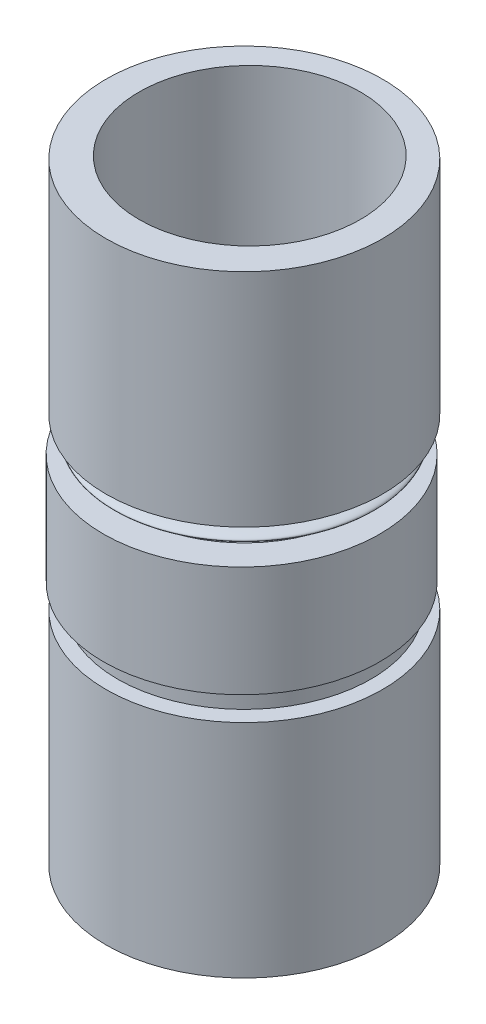
from build123d import *

# Parameters (mm, degrees)
SKETCH_2_R      = 6.25
SKETCH_2_R_2    = 5
EXTRUDE_1_DEPTH = 10
EXTRUDE_START   = 0.15
SKETCH_3_R      = 5.731622833
EXTRUDE_2_DEPTH = 0.75
EXTRUDE_START_2 = 0.25
SKETCH_4_R      = 6.25
SKETCH_4_R_2    = 5
EXTRUDE_3_DEPTH = 5
EXTRUDE_START_3 = 1.5
SKETCH_6_R      = 6.25
SKETCH_6_R_2    = 5
EXTRUDE_4_DEPTH = 10


with BuildPart() as part:
    # 草图2 → 凸台-拉伸1 (new body)
    with BuildSketch(Plane(origin=(0, 0, 0), x_dir=(1, 0, 0), z_dir=(0, 1, 0))):
        Circle(SKETCH_2_R)
        Circle(SKETCH_2_R_2, mode=Mode.SUBTRACT)
    extrude(amount=EXTRUDE_1_DEPTH)


with BuildPart() as body_2:
    # 草图3 → 凸台-拉伸2 (new body)
    with BuildSketch(Plane(origin=(0, 10, 0), x_dir=(1, 0, 0), z_dir=(0, 1, 0)).offset(EXTRUDE_START)):
        Circle(SKETCH_3_R)
    extrude(amount=EXTRUDE_2_DEPTH)


with BuildPart() as body_3:
    # 草图4 → 凸台-拉伸3 (new body)
    with BuildSketch(Plane(origin=(0, 10.9, 0), x_dir=(1, 0, 0), z_dir=(0, 1, 0)).offset(EXTRUDE_START_2)):
        with Locations((0, -0.121569805)):
            Circle(SKETCH_4_R)
        Circle(SKETCH_4_R_2, mode=Mode.SUBTRACT)
    extrude(amount=EXTRUDE_3_DEPTH)


with BuildPart() as body_4:
    # 草图5 → 旋转1 (revolve)
    with BuildSketch(Plane.XY):
        with BuildLine():
            Line((0, 17.664448142), (0, 16.15))
            add(Edge.make_bspline(
                [(0, 16.15), (11.757782886, 16.806663198), (0, 17.664448142)],
                knots=[0, 0, 0, 1, 1, 1], degree=2))
        make_face()
    revolve(axis=Axis((0, 0, 0), (0, 1, 0)))


with BuildPart() as body_5:
    # 草图6 → 凸台-拉伸4 (new body)
    with BuildSketch(Plane(origin=(0, 16.15, 0), x_dir=(1, 0, 0), z_dir=(0, 1, 0)).offset(EXTRUDE_START_3)):
        Circle(SKETCH_6_R)
        with Locations((0, 0.247187806)):
            Circle(SKETCH_6_R_2, mode=Mode.SUBTRACT)
    extrude(amount=EXTRUDE_4_DEPTH)


solid = Compound([part.part, body_2.part, body_3.part, body_4.part, body_5.part])
